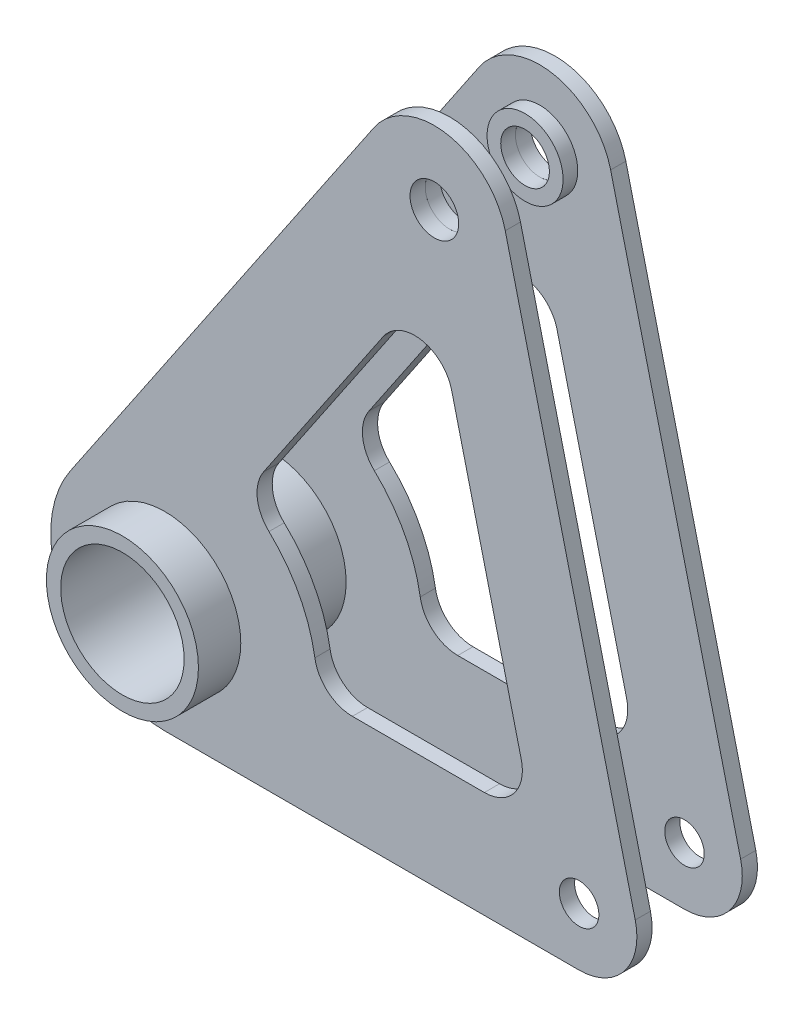
from build123d import *

# Parameters (mm, degrees)
BEARING_BACK_STOP_DEPTH      = 1.27
BEARING_BACK_STOP_DEPTH_BACK = 1.27
SKETCH3_R                    = 12.7
SKETCH3_R_2                  = 9.525
BEARING_MOUNT_DEPTH          = 17.145
BEARING_MOUNT_DEPTH_BACK     = 17.145
SKETCH1_R                    = 12.7
SKETCH1_R_2                  = 10.3124
BELLCRANK_START              = 7.5311
SKETCH4_R                    = 4.064
SKETCH4_R_2                  = 3.302
SKETCH4_R_3                  = 12.7
BELLCRANK_PLATE_DEPTH        = 2.54
SKETCH5_R                    = 6.35
SKETCH5_R_2                  = 4.064
DAMPER_WASHER_DEPTH          = 2.4511


with BuildPart() as part:
    # Sketch3 → Bearing Back Stop (new, two sides: drawn at the far end of the back side and taken through both)
    with BuildSketch(Plane.XY.offset(-BEARING_BACK_STOP_DEPTH_BACK)):
        Circle(SKETCH3_R)
        Circle(SKETCH3_R_2, mode=Mode.SUBTRACT)
    extrude(amount=BEARING_BACK_STOP_DEPTH + BEARING_BACK_STOP_DEPTH_BACK)

    # Sketch1 → Bearing Mount (add, two sides: drawn at the far end of the back side and taken through both)
    with BuildSketch(Plane.XY.offset(-BEARING_MOUNT_DEPTH_BACK)):
        Circle(SKETCH1_R)
        Circle(SKETCH1_R_2, mode=Mode.SUBTRACT)
    extrude(amount=BEARING_MOUNT_DEPTH + BEARING_MOUNT_DEPTH_BACK)


with BuildPart() as body_2:
    # Sketch4 → Bellcrank Plate (new body)
    with BuildSketch(Plane.XY.offset(BELLCRANK_START)):
        with BuildLine():
            Line((-15.781313692, 10.67017517), (34.934592494, 85.679592718))
            ThreePointArc((34.934592494, 85.679592718), (47.186460576, 90.851284893), (56.878127765, 81.744899299))
            Line((56.878127765, 81.744899299), (78.590983305, -7.106743537))
            ThreePointArc((78.590983305, -7.106743537), (76.806863181, -15.358113112), (69.214883486, -19.05))
            Line((69.214883486, -19.05), (0, -19.05))
            ThreePointArc((0, -19.05), (-16.825120163, -8.934082578), (-15.781313692, 10.67017517))
        make_face()
        with Locations((45.034633256, 78.850680609)):
            Circle(SKETCH4_R, mode=Mode.SUBTRACT)
        with Locations((69.214883486, -9.398)):
            Circle(SKETCH4_R_2, mode=Mode.SUBTRACT)
        Circle(SKETCH4_R_3, mode=Mode.SUBTRACT)
        with BuildLine():
            Line((53.387578963, -1.27), (31.340965205, -1.27))
            ThreePointArc((31.340965205, -1.27), (27.225694862, 0.243984078), (25.072772164, 4.064))
            ThreePointArc((25.072772164, 4.064), (22.433493551, 11.912110103), (17.41029553, 18.494366968))
            ThreePointArc((17.41029553, 18.494366968), (15.451617983, 22.417526417), (16.502431515, 26.674683767))
            Line((16.502431515, 26.674683767), (36.493731583, 56.242050042))
            ThreePointArc((36.493731583, 56.242050042), (42.874912876, 58.935639716), (47.922656203, 54.192730553))
            Line((47.922656203, 54.192730553), (59.556065687, 6.587405568))
            ThreePointArc((59.556065687, 6.587405568), (58.382302447, 1.158872953), (53.387578963, -1.27))
        make_face(mode=Mode.SUBTRACT)
    extrude(amount=BELLCRANK_PLATE_DEPTH)


with BuildPart() as body_3:
    # Sketch5 → Damper Washer (new body)
    with BuildSketch(Plane(origin=(0, 0, 7.5311), x_dir=(-1, 0, 0), z_dir=(0, 0, -1))):
        with Locations((-45.034633256, 78.850680609)):
            Circle(SKETCH5_R)
        with Locations((-45.034633256, 78.850680609)):
            Circle(SKETCH5_R_2, mode=Mode.SUBTRACT)
    extrude(amount=DAMPER_WASHER_DEPTH)


with BuildPart() as body_4:
    # Bellcrank Mirror: mirrored copy
    add(body_2.part.mirror(Plane.XY))


with BuildPart() as body_5:
    # Bellcrank Mirror 2: mirrored copy
    add(body_3.part.mirror(Plane.XY))


solid = Compound([part.part, body_2.part, body_3.part, body_4.part, body_5.part])
